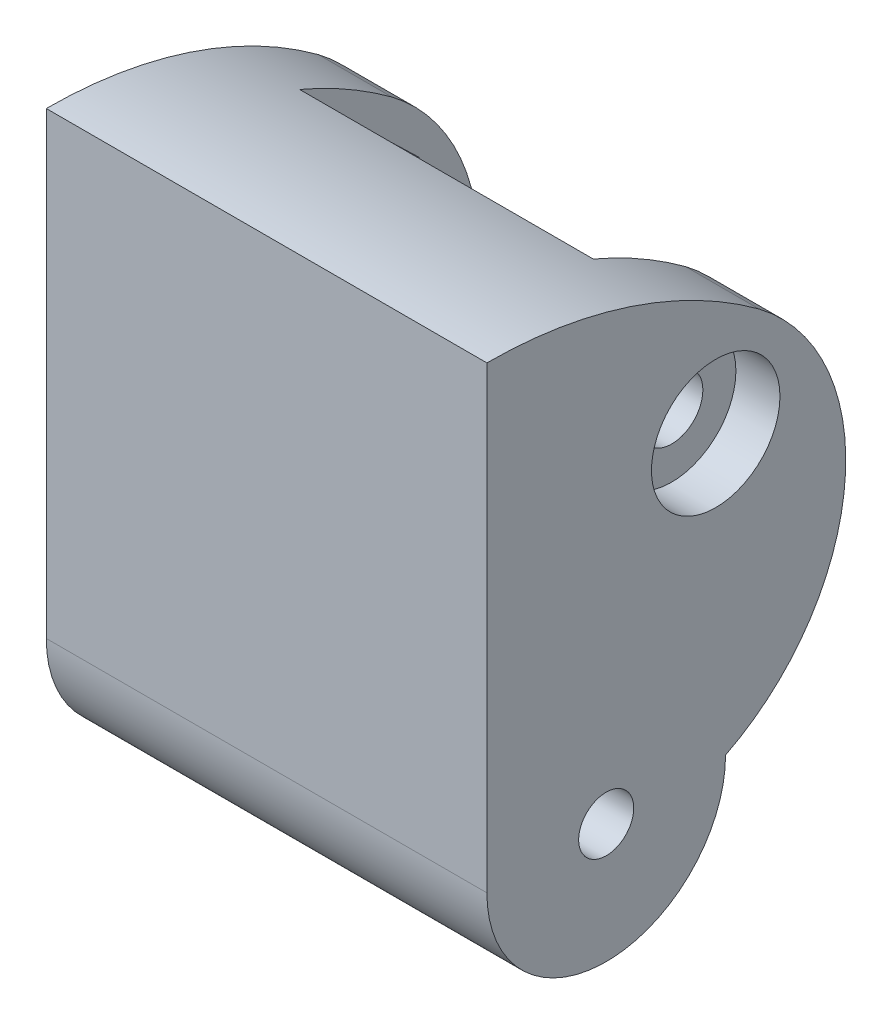
from build123d import *

# Parameters (mm, degrees)
SZKIC5_R                                             = 1.5
DODANIE_WYCI_GNI_CIE2_DEPTH                          = 24
POG_BIENIE_WALCOWE_POD_M3_WKR_T_DO_CZ_CI_D           = 3.4
POG_BIENIE_WALCOWE_POD_M3_WKR_T_DO_CZ_CI_CBORE_D     = 7
POG_BIENIE_WALCOWE_POD_M3_WKR_T_DO_CZ_CI_CBORE_DEPTH = 2.4
SZKIC14_W                                            = 16
SZKIC14_H                                            = 17
WYTNIJ_WYCI_GNI_CIE1_DEPTH                           = 9
WYTNIJ_WYCI_GNI_CIE1_DEPTH_BACK                      = 24
WYTNIJ_WYCI_GNI_CIE2_DEPTH                           = 8


with BuildPart() as part:
    # Szkic5 → Dodanie-wyciągnięcie2 (new body)
    with BuildSketch(Plane(origin=(0, 0, 0), x_dir=(0, 0, -1), z_dir=(1, 0, 0))):
        with BuildLine():
            Line((-12.908163265, 21.275510204), (-12.908163265, -3.724489796))
            ThreePointArc((-12.908163265, -3.724489796), (-6.408163265, -10.224489796), (0.091836735, -3.724489796))
            ThreePointArc((0.091836735, -3.724489796), (6.591813696, 5.834724726), (1.9156302, 16.406460189))
            ThreePointArc((1.9156302, 16.406460189), (-5.106681022, 20.027075938), (-12.908163265, 21.275510204))
        make_face()
        with Locations((-6.408163265, -3.724489796)):
            Circle(SZKIC5_R, mode=Mode.SUBTRACT)
    extrude(amount=DODANIE_WYCI_GNI_CIE2_DEPTH)

    # Pogłębienie walcowe pod M3 wkręt do części metalowych z łbem stożkowym ściętym1 (through all)
    with Locations(Plane(origin=(24, 0, 0), x_dir=(0, 0, -1), z_dir=(1, 0, 0))):
        with Locations((-0.443639472, 11.715274148)):
            CounterBoreHole(POG_BIENIE_WALCOWE_POD_M3_WKR_T_DO_CZ_CI_D / 2, POG_BIENIE_WALCOWE_POD_M3_WKR_T_DO_CZ_CI_CBORE_D / 2, POG_BIENIE_WALCOWE_POD_M3_WKR_T_DO_CZ_CI_CBORE_DEPTH)

    # Szkic14 → Wytnij-wyciągnięcie1 (cut, two sides)
    with BuildSketch(Plane.XY) as wytnij_wyci_gni_cie1_sk:
        with Locations((12, 10.775510204)):
            Rectangle(SZKIC14_W, SZKIC14_H)
    extrude(amount=WYTNIJ_WYCI_GNI_CIE1_DEPTH, mode=Mode.SUBTRACT)
    extrude(wytnij_wyci_gni_cie1_sk.sketch, amount=-WYTNIJ_WYCI_GNI_CIE1_DEPTH_BACK, mode=Mode.SUBTRACT)

    # Szkic18 → Wytnij-wyciągnięcie2 (cut)
    with BuildSketch(Plane.ZY):
        Polygon((1.412173102, 7.834302284), (4.288926512, 10.613562944), (3.320392883, 14.494534808), (-0.524894158, 15.596246012), (-3.401647568, 12.816985352), (-2.433113939, 8.936013488), align=None)
    extrude(amount=-WYTNIJ_WYCI_GNI_CIE2_DEPTH, mode=Mode.SUBTRACT)


solid = part.part
